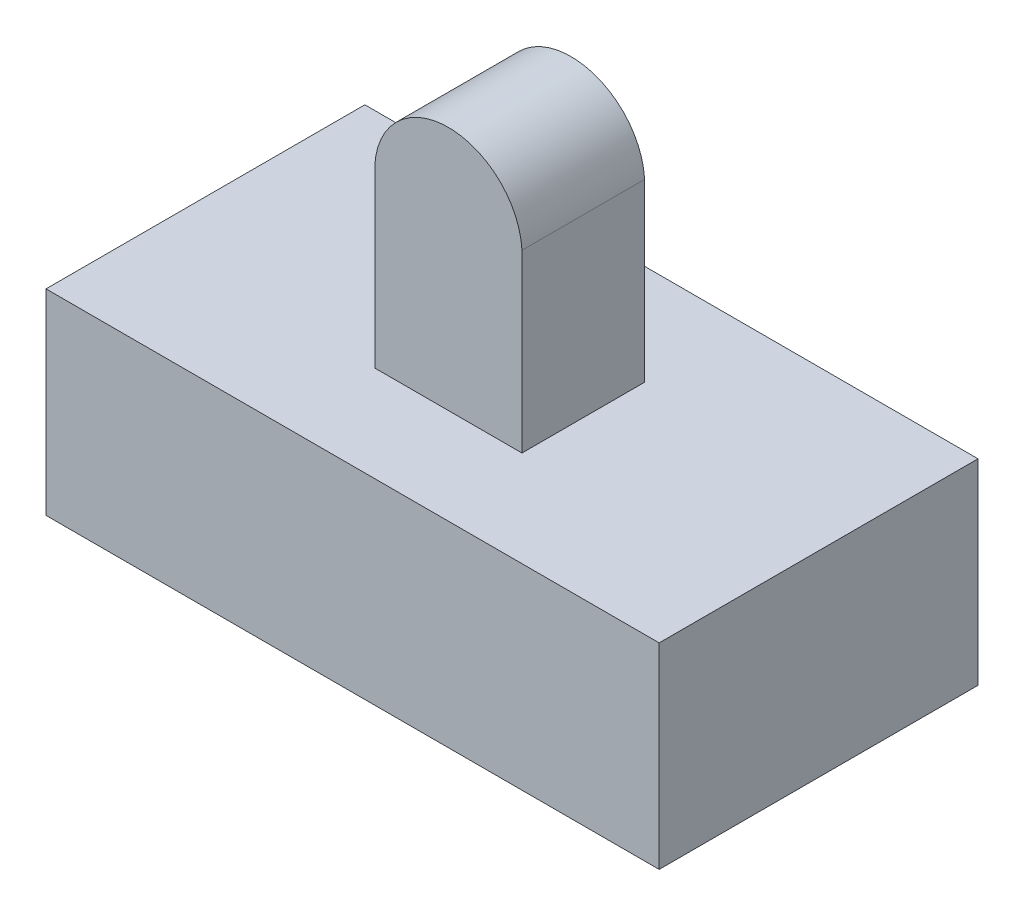
from build123d import *

# Parameters (mm, degrees)
SKETCH3_W           = 25
SKETCH3_H           = 13
BOSS_EXTRUDE1_DEPTH = 8
SKETCH4_W           = 6
SKETCH4_H           = 3.1
CUT_EXTRUDE1_DEPTH  = 5
SKETCH5_W           = 6
SKETCH5_H           = 5
BOSS_EXTRUDE2_DEPTH = 10
CUT_EXTRUDE2_DEPTH  = 10


with BuildPart() as part:
    # Sketch3 → Boss-Extrude1 (new body)
    with BuildSketch(Plane(origin=(0, 0, 0), x_dir=(1, 0, 0), z_dir=(0, 1, 0))):
        with Locations((6.675257732, -1.809278351)):
            Rectangle(SKETCH3_W, SKETCH3_H)
    extrude(amount=BOSS_EXTRUDE1_DEPTH)

    # Sketch4 → Cut-Extrude1 (cut)
    with BuildSketch(Plane.XZ):
        with Locations((6.367389679, 1.844147545)):
            Rectangle(SKETCH4_W, SKETCH4_H)
    extrude(amount=-CUT_EXTRUDE1_DEPTH, mode=Mode.SUBTRACT)

    # Sketch5 → Boss-Extrude2 (add)
    with BuildSketch(Plane(origin=(0, 8, 0), x_dir=(1, 0, 0), z_dir=(0, 1, 0))):
        with Locations((6.675257732, -1.902518117)):
            Rectangle(SKETCH5_W, SKETCH5_H)
    extrude(amount=BOSS_EXTRUDE2_DEPTH)

    # Sketch6 → Cut-Extrude2 (cut)
    with BuildSketch(Plane(origin=(0, 0, -0.597481883), x_dir=(-1, 0, 0), z_dir=(0, 0, -1))):
        with BuildLine():
            Line((-3.675257732, 18), (-6.675257732, 18))
            ThreePointArc((-6.675257732, 18), (-4.610198245, 17.177859086), (-3.675257732, 15.161358998))
            Line((-3.675257732, 15.161358998), (-3.675257732, 18))
        make_face()
        with BuildLine():
            Line((-9.675257732, 18), (-9.675257732, 15.161358998))
            ThreePointArc((-9.675257732, 15.161358998), (-8.740317219, 17.177859086), (-6.675257732, 18))
            Line((-6.675257732, 18), (-9.675257732, 18))
        make_face()
    extrude(amount=-CUT_EXTRUDE2_DEPTH, mode=Mode.SUBTRACT)


solid = part.part
